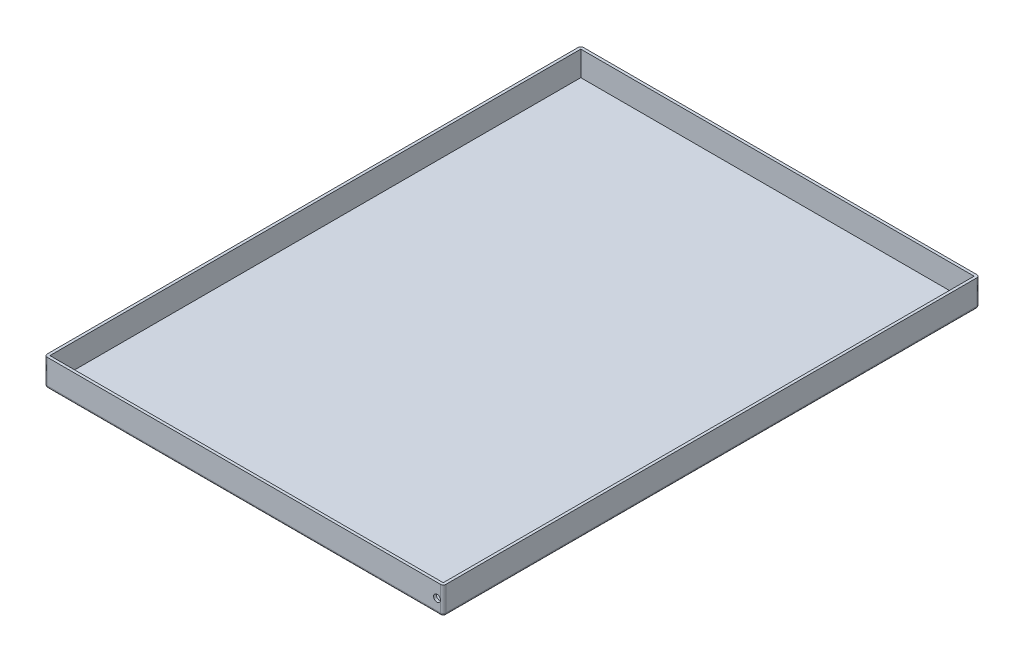
from build123d import *

# Parameters (mm, degrees)
SKETCH1_W             = 290
SKETCH1_H             = 390
BOSS_EXTRUDE1_DEPTH   = 20
SKETCH2_W             = 286
SKETCH2_H             = 386
CUT_EXTRUDE1_DEPTH    = 18
FILLET1_R             = 2
SKETCH3_R             = 2.5
CUT_EXTRUDE2_DEPTH    = 391
SKETCH4_W             = 30
SKETCH4_H             = 40
BOSS_EXTRUDE2_DEPTH   = 5
BOSS_EXTRUDE2_2_DEPTH = 5
FILLET2_R             = 2
FILLET3_R             = 2


with BuildPart() as part:
    # Sketch1 → Boss-Extrude1 (new body)
    with BuildSketch(Plane(origin=(0, 0, 0), x_dir=(1, 0, 0), z_dir=(0, 1, 0))):
        with Locations((145, 195)):
            Rectangle(SKETCH1_W, SKETCH1_H)
    extrude(amount=BOSS_EXTRUDE1_DEPTH)

    # Sketch2 → Cut-Extrude1 (cut)
    with BuildSketch(Plane(origin=(0, 20, 0), x_dir=(1, 0, 0), z_dir=(0, 1, 0))):
        with Locations((145, 195)):
            Rectangle(SKETCH2_W, SKETCH2_H)
    extrude(amount=-CUT_EXTRUDE1_DEPTH, mode=Mode.SUBTRACT)

    # Fillet1
    fillet1_edges = [part.edges().sort_by_distance(p)[0] for p in [
        (145, 0, -390),
        (290, 0, -195),
        (145, 0, 0),
        (0, 0, -195),
        (0, 10, -390),
        (290, 10, -390),
        (290, 10, 0),
        (0, 10, 0),
    ]]
    fillet(fillet1_edges, radius=FILLET1_R)

    # Sketch3 → Cut-Extrude2 (cut, through all)
    with BuildSketch(Plane(origin=(0, 0, -390), x_dir=(-1, 0, 0), z_dir=(0, 0, -1))):
        with Locations((-285.5, 10)):
            Circle(SKETCH3_R)
    extrude(amount=-CUT_EXTRUDE2_DEPTH, mode=Mode.SUBTRACT)


with BuildPart() as body_2:
    # Sketch4 → Boss-Extrude2 (new body)
    with BuildSketch(Plane(origin=(0, 0, 0), x_dir=(-1, 0, 0), z_dir=(0, -1, 0))):
        with Locations((-47, 95)):
            Rectangle(SKETCH4_W, SKETCH4_H)
    extrude(amount=BOSS_EXTRUDE2_DEPTH)

    # Fillet2
    fillet2_edges = [body_2.edges().sort_by_distance(p)[0] for p in [
        (62, -5, -95),
        (47, -5, -75),
        (32, -5, -95),
        (32, -2.5, -75),
        (62, -2.5, -75),
        (62, -2.5, -115),
        (32, -2.5, -115),
        (47, -5, -115),
    ]]
    fillet(fillet2_edges, radius=FILLET2_R)


with BuildPart() as body_3:
    # Sketch4 → Boss-Extrude2 2 (new body)
    with BuildSketch(Plane(origin=(0, 0, 0), x_dir=(-1, 0, 0), z_dir=(0, -1, 0))):
        with Locations((-47, 295)):
            Rectangle(SKETCH4_W, SKETCH4_H)
    extrude(amount=BOSS_EXTRUDE2_2_DEPTH)

    # Fillet3
    fillet3_edges = [body_3.edges().sort_by_distance(p)[0] for p in [
        (32, -5, -295),
        (47, -5, -315),
        (62, -5, -295),
        (47, -5, -275),
        (32, -2.5, -275),
        (62, -2.5, -275),
        (62, -2.5, -315),
        (32, -2.5, -315),
    ]]
    fillet(fillet3_edges, radius=FILLET3_R)


solid = Compound([part.part, body_2.part, body_3.part])
